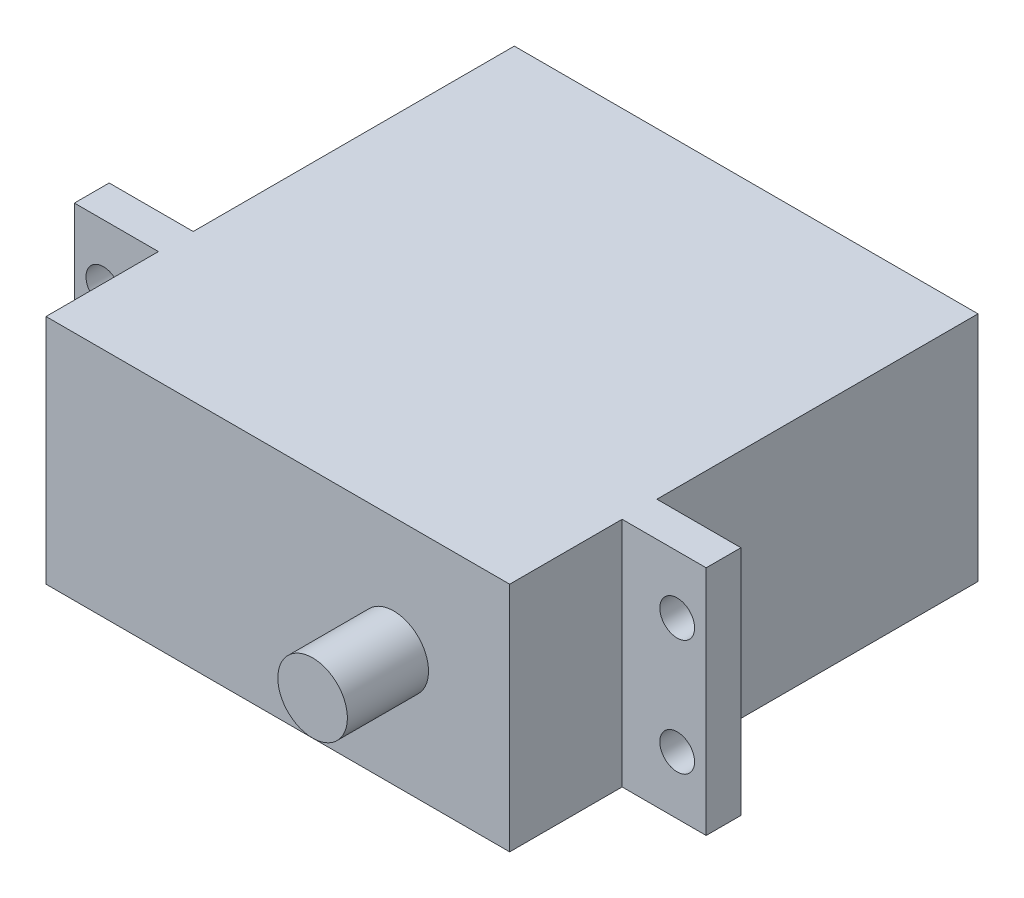
from build123d import *

# Parameters (mm, degrees)
SKETCH1_W           = 40
SKETCH1_H           = 40.4
BOSS_EXTRUDE1_DEPTH = 20
SKETCH3_W           = 3
SKETCH3_H           = 20
BOSS_EXTRUDE2_DEPTH = 7.25
SKETCH5_R           = 1.5
CUT_EXTRUDE1_DEPTH  = 7.25
SKETCH6_R           = 3
BOSS_EXTRUDE3_DEPTH = 7


with BuildPart() as part:
    # Sketch1 → Boss-Extrude1 (new body)
    with BuildSketch(Plane(origin=(0, 0, 0), x_dir=(1, 0, 0), z_dir=(0, 1, 0))):
        with Locations((-7.684478372, -4.939949109)):
            Rectangle(SKETCH1_W, SKETCH1_H)
    extrude(amount=BOSS_EXTRUDE1_DEPTH)

    # Sketch3 → Boss-Extrude2 (add)
    with BuildSketch(Plane(origin=(12.315521628, 0, 0), x_dir=(0, 0, -1), z_dir=(1, 0, 0))):
        with Locations((-13.939949109, 10)):
            Rectangle(SKETCH3_W, SKETCH3_H)
    boss_extrude2 = extrude(amount=BOSS_EXTRUDE2_DEPTH)

    # Mirror1: Boss-Extrude2 across plane
    add(boss_extrude2.mirror(Plane.ZY.offset(7.684478372)))

    # Sketch5 → Cut-Extrude1 (cut)
    with BuildSketch(Plane.XY.offset(15.439949109)):
        with Locations((17.065521628, 15)):
            Circle(SKETCH5_R)
        with Locations((17.065521628, 5)):
            Circle(SKETCH5_R)
        with Locations((-32.434478372, 15)):
            Circle(SKETCH5_R)
        with Locations((-32.434478372, 5)):
            Circle(SKETCH5_R)
    extrude(amount=-CUT_EXTRUDE1_DEPTH, mode=Mode.SUBTRACT)

    # Sketch6 → Boss-Extrude3 (add)
    with BuildSketch(Plane.XY.offset(25.139949109)):
        with Locations((2.315521628, 10)):
            Circle(SKETCH6_R)
    extrude(amount=BOSS_EXTRUDE3_DEPTH)


solid = part.part
